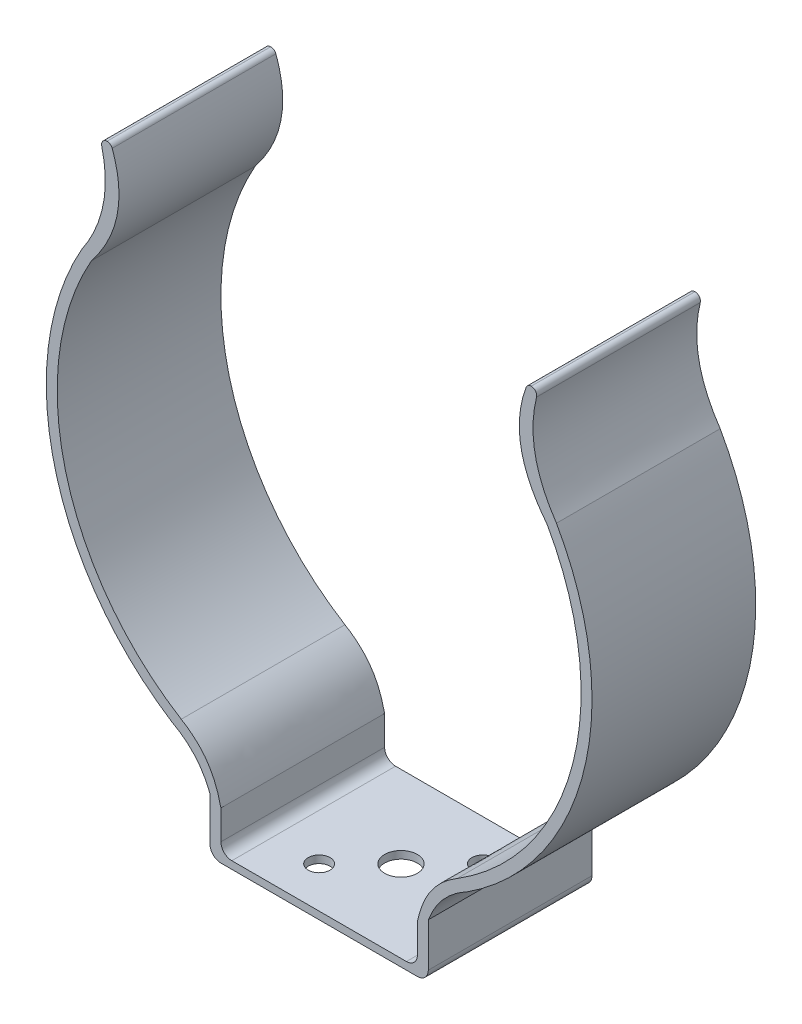
from build123d import *

# Parameters (mm, degrees)
BOSS_EXTRUDE1_DEPTH = 38.1
SKETCH2_R           = 3.81
SKETCH2_R_2         = 2.54
CUT_EXTRUDE1_DEPTH  = 2.54
FILLET1_R           = 1.27
FILLET2_R           = 2.54
SCALE1_SCALE        = 1.1


with BuildPart() as part:
    # Sketch1 → Boss-Extrude1 (new body)
    with BuildSketch(Plane.XY):
        with BuildLine():
            Line((-51.030503122, 56.023178588), (-48.490503122, 56.023178588))
            add(Edge.make_bspline(
                [(-48.490503122, 56.023178588), (-43.069252532, 42.611394773), (-53.01543557, 30.091280986)],
                knots=[0, 0, 0, 1, 1, 1], degree=2))
            ThreePointArc((-53.01543557, 30.091280986), (-59.06455096, -15.083117047), (-32.096486043, -51.826028053))
            add(Edge.make_bspline(
                [(-32.096486043, -51.826028053), (-26.666596777, -55.080730316), (-24.15411201, -59.274056829), (-22.86, -65.092330549)],
                knots=[0, 0, 0, 0, 1, 1, 1, 1], degree=3))
            Line((-22.86, -65.092330549), (-22.86, -74.449178354))
            Line((-22.86, -74.449178354), (22.86, -74.449178354))
            Line((22.86, -74.449178354), (22.86, -65.092330549))
            add(Edge.make_bspline(
                [(32.096486043, -51.826028053), (26.666596777, -55.080730316), (24.15411201, -59.274056829), (22.86, -65.092330549)],
                knots=[0, 0, 0, 0, 1, 1, 1, 1], degree=3))
            ThreePointArc((32.096486043, -51.826028053), (59.06455096, -15.083117047), (53.01543557, 30.091280986))
            add(Edge.make_bspline(
                [(48.490503122, 56.023178588), (43.069252532, 42.611394773), (53.01543557, 30.091280986)],
                knots=[0, 0, 0, 1, 1, 1], degree=2))
            Line((48.490503122, 56.023178588), (51.030503122, 56.023178588))
            add(Edge.make_bspline(
                [(55.224412052, 31.34508436), (47.144066751, 43.196956405), (51.030503122, 56.023178588)],
                knots=[0, 0, 0, 1, 1, 1], degree=2))
            ThreePointArc((55.224412052, 31.34508436), (61.651768505, -15.208860583), (34.310656711, -53.432469867))
            add(Edge.make_bspline(
                [(34.310656711, -53.432469867), (27.932475889, -56.813983763), (25.4, -63.5)],
                knots=[0, 0, 0, 1, 1, 1], degree=2))
            Line((25.4, -63.5), (25.4, -76.2))
            Line((25.4, -76.2), (-25.4, -76.2))
            Line((-25.4, -76.2), (-25.4, -63.5))
            add(Edge.make_bspline(
                [(-34.310656711, -53.432469867), (-27.932475889, -56.813983763), (-25.4, -63.5)],
                knots=[0, 0, 0, 1, 1, 1], degree=2))
            ThreePointArc((-34.310656711, -53.432469867), (-61.651768505, -15.208860583), (-55.224412052, 31.34508436))
            add(Edge.make_bspline(
                [(-55.224412052, 31.34508436), (-47.144066751, 43.196956405), (-51.030503122, 56.023178588)],
                knots=[0, 0, 0, 1, 1, 1], degree=2))
        make_face()
    extrude(amount=BOSS_EXTRUDE1_DEPTH)

    # Sketch2 → Cut-Extrude1 (cut)
    with BuildSketch(Plane(origin=(0, -74.449178354, 0), x_dir=(1, 0, 0), z_dir=(0, 1, 0))):
        with Locations((0, -19.05)):
            Circle(SKETCH2_R)
        with Locations((9.525, -9.525)):
            Circle(SKETCH2_R_2)
        with Locations((-9.525, -28.575)):
            Circle(SKETCH2_R_2)
    extrude(amount=-CUT_EXTRUDE1_DEPTH, mode=Mode.SUBTRACT)

    # Fillet1
    fillet1_edges = [part.edges().sort_by_distance(p)[0] for p in [
        (51.030503122, 56.023178588, 19.05),
        (48.490503122, 56.023178588, 19.05),
        (-48.490503122, 56.023178588, 19.05),
        (-51.030503122, 56.023178588, 19.05),
    ]]
    fillet(fillet1_edges, radius=FILLET1_R)

    # Fillet2
    fillet2_edges = [part.edges().sort_by_distance(p)[0] for p in [
        (-22.86, -74.449178354, 19.05),
        (22.86, -74.449178354, 19.05),
        (25.4, -76.2, 19.05),
        (-25.4, -76.2, 19.05),
    ]]
    fillet(fillet2_edges, radius=FILLET2_R)


with BuildPart() as part_1:
    # Scale1: scaled about (0, 0, 0)
    add(part.part.scale(SCALE1_SCALE))


solid = part_1.part
